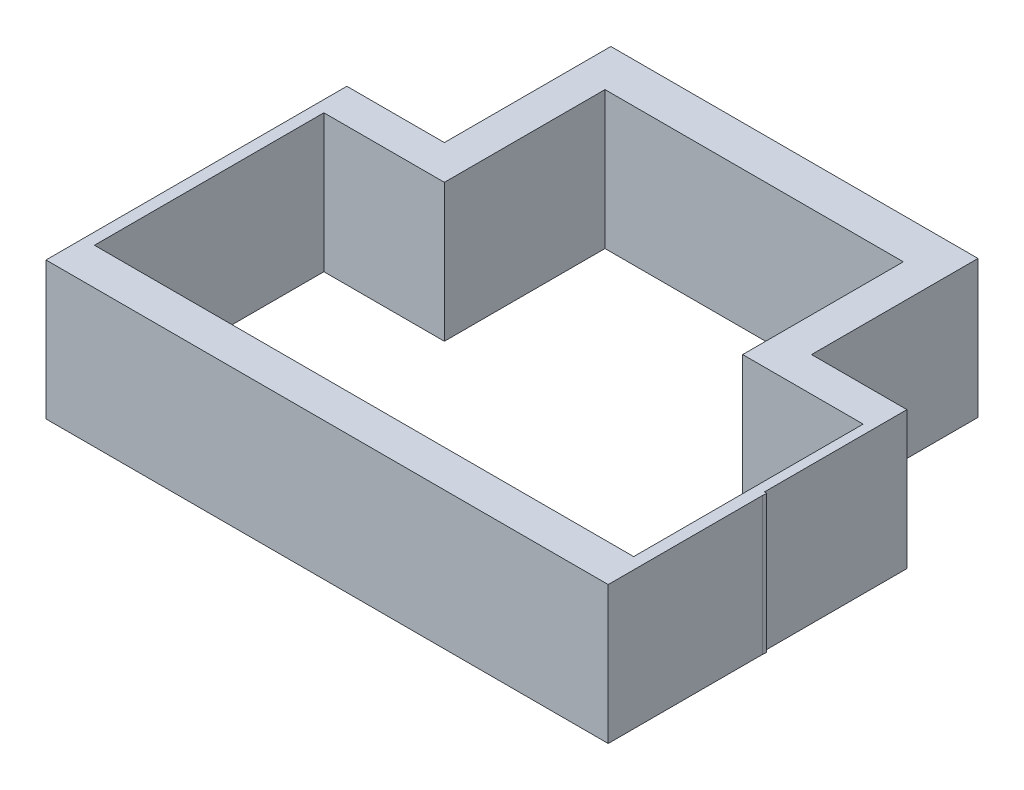
from build123d import *

# Parameters (mm, degrees)
SKETCH1_W           = 24.5
SKETCH1_H           = 13.110526316
SKETCH1_W_2         = 23.5
SKETCH1_H_2         = 10
BOSS_EXTRUDE1_DEPTH = 6
BOSS_EXTRUDE2_DEPTH = 6
SKETCH3_W           = 13.982681085
SKETCH3_H           = 4.437803864
CUT_EXTRUDE1_DEPTH  = 11
SKETCH4_W           = 0.982681085
SKETCH4_H           = 2.509369157
BOSS_EXTRUDE3_DEPTH = 6
SKETCH5_W           = 4.892282449
SKETCH5_H           = 6
BOSS_EXTRUDE4_DEPTH = 3.3
FILLET1_R           = 1.5
SKETCH6_W           = 3.982650634
SKETCH6_H           = 6.804776745
CUT_EXTRUDE2_DEPTH  = 10


with BuildPart() as part:
    # Sketch1 → Boss-Extrude1 (new body)
    with BuildSketch(Plane(origin=(0, 0, 0), x_dir=(1, 0, 0), z_dir=(0, 1, 0))):
        with Locations((-3.853684211, 3.800526316)):
            Rectangle(SKETCH1_W, SKETCH1_H)
        with Locations((-3.853684211, 3.855789474)):
            Rectangle(SKETCH1_W_2, SKETCH1_H_2, mode=Mode.SUBTRACT)
    extrude(amount=BOSS_EXTRUDE1_DEPTH)

    # Sketch2 → Boss-Extrude2 (add)
    with BuildSketch(Plane(origin=(0, 6, 0), x_dir=(1, 0, 0), z_dir=(0, 1, 0))):
        Polygon((-10.353684211, 10.355789474), (-10.353684211, 15.855789474), (2.646315789, 15.855789474), (2.646315789, 10.355789474), (4.146315789, 10.355789474), (4.146315789, 17.610127639), (-11.853684211, 17.610127639), (-11.853684211, 10.355789474), align=None)
    extrude(amount=-BOSS_EXTRUDE2_DEPTH)

    # Sketch3 → Cut-Extrude1 (cut)
    with BuildSketch(Plane(origin=(0, 6, 0), x_dir=(1, 0, 0), z_dir=(0, 1, 0))):
        with Locations((-3.362343669, 9.146256699)):
            Rectangle(SKETCH3_W, SKETCH3_H)
    extrude(amount=-CUT_EXTRUDE1_DEPTH, mode=Mode.SUBTRACT)

    # Sketch4 → Boss-Extrude3 (add)
    with BuildSketch(Plane(origin=(0, 6, 0), x_dir=(1, 0, 0), z_dir=(0, 1, 0))):
        with Locations((3.137656332, 10.110474052)):
            Rectangle(SKETCH4_W, SKETCH4_H)
    extrude(amount=-BOSS_EXTRUDE3_DEPTH)

    # Sketch5 → Boss-Extrude4 (add)
    with BuildSketch(Plane(origin=(8.396315789, 0, 0), x_dir=(0, 0, -1), z_dir=(1, 0, 0))):
        with Locations((7.90964825, 3)):
            Rectangle(SKETCH5_W, SKETCH5_H)
    extrude(amount=BOSS_EXTRUDE4_DEPTH)

    # Fillet1
    fillet1_edges = [part.edges().sort_by_distance(p)[0] for p in [
        (8.396315789, 3, -5.463507025),
    ]]
    fillet(fillet1_edges, radius=FILLET1_R)

    # Sketch6 → Cut-Extrude2 (cut)
    with BuildSketch(Plane(origin=(0, 6, 0), x_dir=(1, 0, 0), z_dir=(0, 1, 0))):
        with Locations((10.294706848, 7.545396136)):
            Rectangle(SKETCH6_W, SKETCH6_H)
    extrude(amount=-CUT_EXTRUDE2_DEPTH, mode=Mode.SUBTRACT)


solid = part.part
